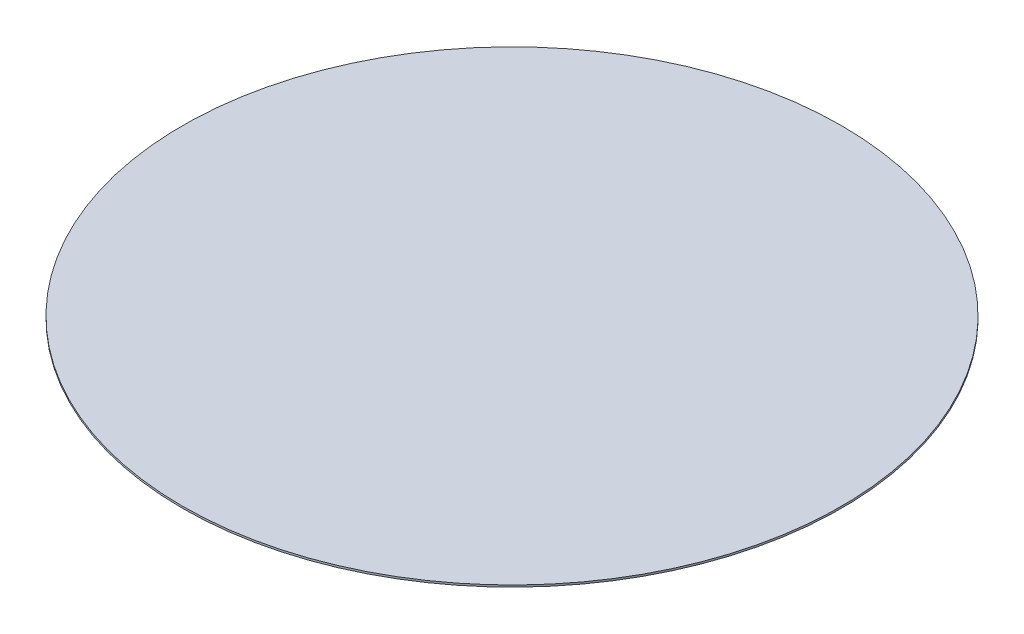
from build123d import *

# Parameters (mm, degrees)
SKETCH1_R           = 175
BOSS_EXTRUDE1_DEPTH = 1


with BuildPart() as part:
    # Sketch1 → Boss-Extrude1 (new body)
    with BuildSketch(Plane(origin=(0, 0, 0), x_dir=(1, 0, 0), z_dir=(0, 1, 0))):
        Circle(SKETCH1_R)
    extrude(amount=BOSS_EXTRUDE1_DEPTH)


solid = part.part
